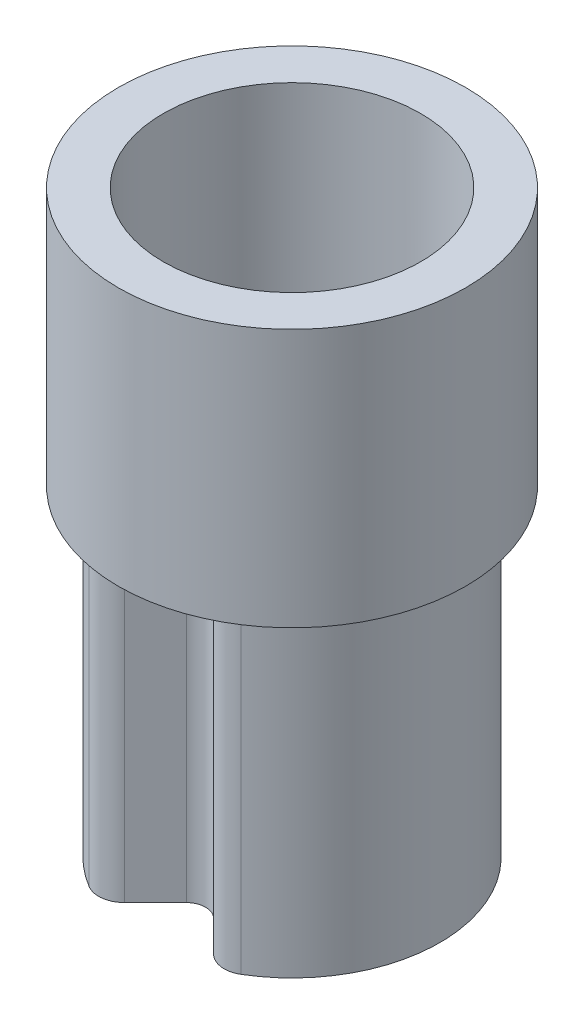
from build123d import *

# Parameters (mm, degrees)
BOSS_EXTRUDE1_DEPTH = 2.5
FILLET1_R           = 0.05
FILLET2_R           = 0.2
SKETCH2_R           = 1.35
SKETCH2_R_2         = 1
BOSS_EXTRUDE2_DEPTH = 2.01


with BuildPart() as part:
    # Sketch1 → Boss-Extrude1 (new body)
    with BuildSketch(Plane(origin=(0, 0, 0), x_dir=(1, 0, 0), z_dir=(0, 1, 0))):
        with BuildLine():
            Line((-0.448807004, -1.058807004), (-0.106066017, -0.716066017))
            ThreePointArc((-0.106066017, -0.716066017), (0, -0.672132034), (0.106066017, -0.716066017))
            Line((0.106066017, -0.716066017), (0.448807004, -1.058807004))
            ThreePointArc((0.448807004, -1.058807004), (0, 1.15), (-0.448807004, -1.058807004))
        make_face()
        with BuildLine():
            Line((-0.479612457, -0.877480422), (-0.212132034, -0.61))
            ThreePointArc((-0.212132034, -0.61), (0, -0.522132034), (0.212132034, -0.61))
            Line((0.212132034, -0.61), (0.479612457, -0.877480422))
            ThreePointArc((0.479612457, -0.877480422), (0, 1), (-0.479612457, -0.877480422))
        make_face(mode=Mode.SUBTRACT)
    extrude(amount=BOSS_EXTRUDE1_DEPTH)

    # Fillet1
    fillet1_edges = [part.edges().sort_by_distance(p)[0] for p in [
        (0.479612457, 1.25, 0.877480422),
        (-0.479612457, 1.25, 0.877480422),
    ]]
    fillet(fillet1_edges, radius=FILLET1_R)

    # Fillet2
    fillet2_edges = [part.edges().sort_by_distance(p)[0] for p in [
        (-0.448807004, 1.25, 1.058807004),
        (0.448807004, 1.25, 1.058807004),
    ]]
    fillet(fillet2_edges, radius=FILLET2_R)

    # Sketch2 → Boss-Extrude2 (add)
    with BuildSketch(Plane(origin=(0, 2.5, 0), x_dir=(1, 0, 0), z_dir=(0, 1, 0))):
        Circle(SKETCH2_R)
        Circle(SKETCH2_R_2, mode=Mode.SUBTRACT)
    extrude(amount=BOSS_EXTRUDE2_DEPTH)


solid = part.part
